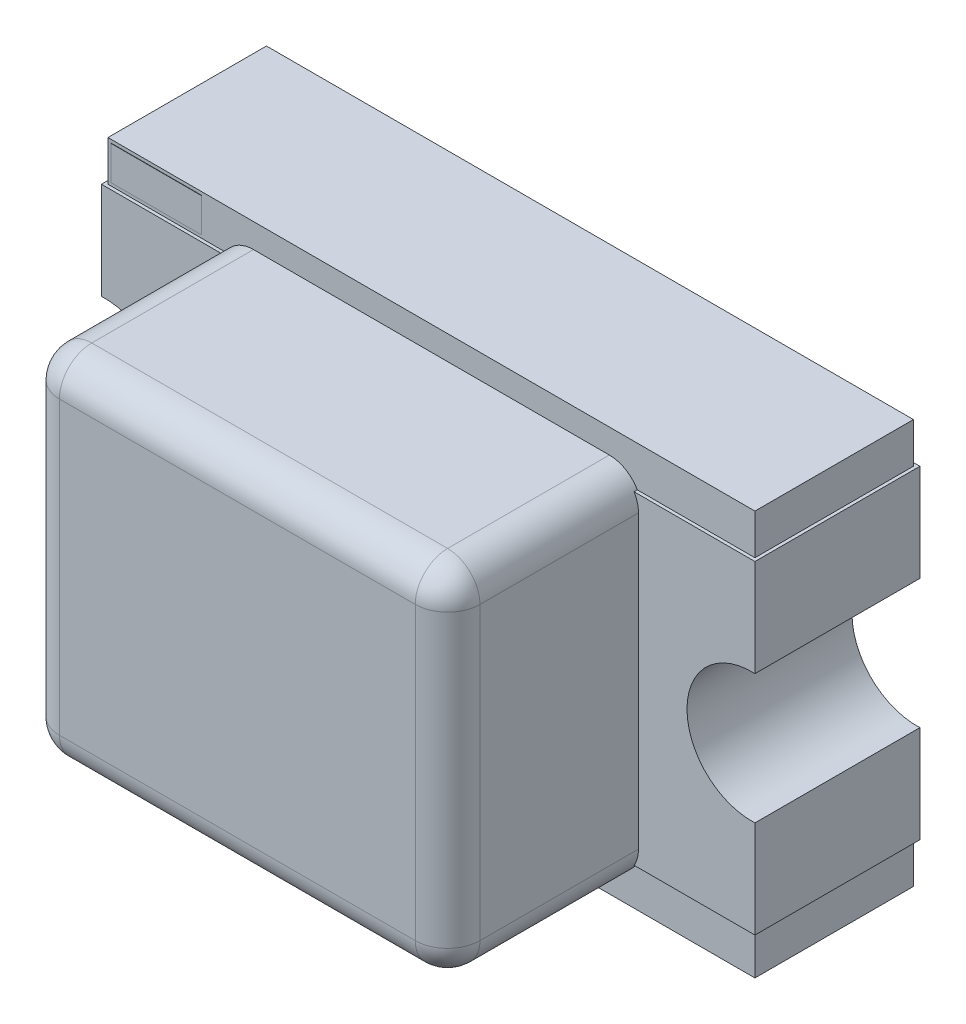
from build123d import *

# Parameters (mm, degrees)
EXTRUDE_START       = 0.01
SKETCH_2_W          = 2
SKETCH_2_H          = 1.25
EXTRUDE_1_DEPTH     = 0.49
SKETCH_3_W          = 0.41
SKETCH_3_H          = 1
EXTRUDE_2_DEPTH     = 0.51
EXTRUDE_START_2     = 0.5
SKETCH_4_W          = 1.3
SKETCH_4_H          = 1.1
EXTRUDE_3_DEPTH     = 0.6
FILLET_1_R          = 0.1
SKETCH_5_W          = 0.28
SKETCH_5_H          = 0.105
EXTRUDE_4_DEPTH     = 0.001
SKETCH_6_R          = 0.2
CUT_EXTRUDE_2_DEPTH = 0.52


with BuildPart() as part:
    # Эскиз2 → Бобышка-Вытянуть1 (new body)
    with BuildSketch(Plane.XY.offset(EXTRUDE_START)):
        Rectangle(SKETCH_2_W, SKETCH_2_H)
    extrude(amount=EXTRUDE_1_DEPTH)

    # Эскиз3 → Бобышка-Вытянуть2 (add)
    with BuildSketch(Plane.XY):
        with Locations((-0.805, 0)):
            Rectangle(SKETCH_3_W, SKETCH_3_H)
        with Locations((0.805, 0)):
            Rectangle(SKETCH_3_W, SKETCH_3_H)
    extrude(amount=EXTRUDE_2_DEPTH)

    # Эскиз4 → Бобышка-Вытянуть3 (add)
    with BuildSketch(Plane.XY.offset(EXTRUDE_START_2)):
        Rectangle(SKETCH_4_W, SKETCH_4_H)
    extrude(amount=EXTRUDE_3_DEPTH)

    # Скругление1
    fillet_1_edges = [part.edges().sort_by_distance(p)[0] for p in [
        (0.65, 0.55, 0.8),
        (-0.65, 0.55, 0.8),
        (0, 0.55, 1.1),
        (0.65, 0, 1.1),
        (0.65, -0.55, 0.8),
        (-0.65, -0.55, 0.8),
        (0, -0.55, 1.1),
        (-0.65, 0, 1.1),
    ]]
    fillet(fillet_1_edges, radius=FILLET_1_R)

    # Эскиз5 → Бобышка-Вытянуть4 (add)
    with BuildSketch(Plane.XY.offset(0.5)):
        with Locations((-0.85, 0.5625)):
            Rectangle(SKETCH_5_W, SKETCH_5_H)
        with Locations((-0.85, -0.5625)):
            Rectangle(SKETCH_5_W, SKETCH_5_H)
    extrude(amount=EXTRUDE_4_DEPTH)

    # Эскиз6 → Вырез-Вытянуть2 (cut)
    with BuildSketch(Plane.XY):
        with Locations((-1, 0)):
            Circle(SKETCH_6_R)
        with Locations((1, 0)):
            Circle(SKETCH_6_R)
    extrude(amount=CUT_EXTRUDE_2_DEPTH, mode=Mode.SUBTRACT)


solid = part.part
